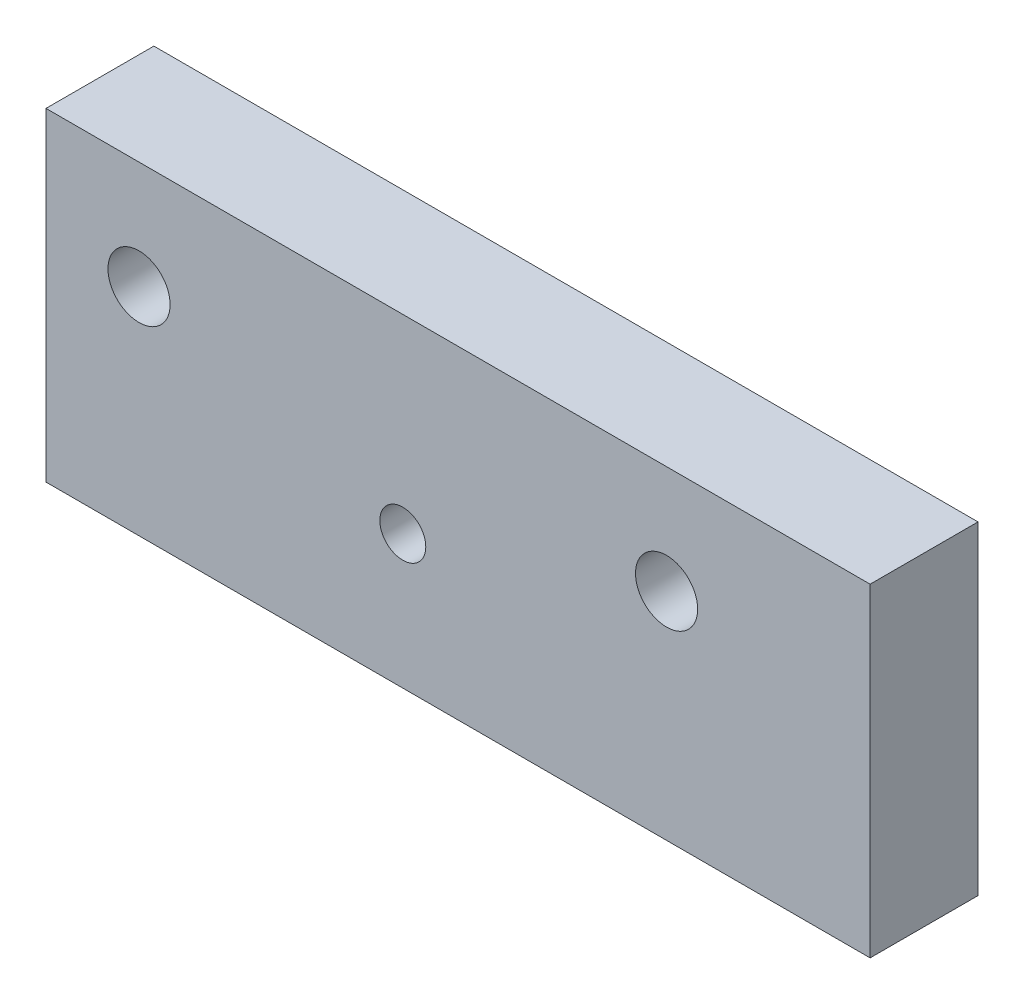
from build123d import *

# Parameters (mm, degrees)
SKETCH1_W                 = 48.505
SKETCH1_H                 = 19.05
BOSS_EXTRUDE1_DEPTH       = 6.35
F_6_CLEARANCE_HOLE1_D     = 3.6576
F_6_CLEARANCE_HOLE1_DEPTH = 9.398
F_6_CLEARANCE_HOLE1_TIP   = 1.0988539
SKETCH4_R                 = 4.7625
CUT_EXTRUDE1_DEPTH        = 2
F_6_32_TAPPED_HOLE1_D     = 2.7051
F_6_32_TAPPED_HOLE1_DEPTH = 10.9728
F_6_32_TAPPED_HOLE1_TIP   = 0.81269403


with BuildPart() as part:
    # Sketch1 → Boss-Extrude1 (new body)
    with BuildSketch(Plane.XY):
        with Locations((3.2525, -3.175)):
            Rectangle(SKETCH1_W, SKETCH1_H)
    extrude(amount=BOSS_EXTRUDE1_DEPTH)

    # 6 Clearance Hole1
    with Locations(Plane.XY.offset(6.35)):
        with Locations((-15.525, 0), (15.525, 0)):
            Hole(F_6_CLEARANCE_HOLE1_D / 2, depth=F_6_CLEARANCE_HOLE1_DEPTH)
            with Locations((0, 0, -(F_6_CLEARANCE_HOLE1_DEPTH + F_6_CLEARANCE_HOLE1_TIP / 2))):  # 118° drill point
                Cone(0, F_6_CLEARANCE_HOLE1_D / 2, F_6_CLEARANCE_HOLE1_TIP, mode=Mode.SUBTRACT)

    # Sketch4 → Cut-Extrude1 (cut)
    with BuildSketch(Plane(origin=(0, 0, 0), x_dir=(-1, 0, 0), z_dir=(0, 0, -1))):
        with Locations((-15.525, 0)):
            Circle(SKETCH4_R)
        with Locations((15.525, 0)):
            Circle(SKETCH4_R)
    extrude(amount=-CUT_EXTRUDE1_DEPTH, mode=Mode.SUBTRACT)

    # 6-32 Tapped Hole1
    with Locations(Plane(origin=(0, 0, 0), x_dir=(-1, 0, 0), z_dir=(0, 0, -1))):
        with Locations((0, -4.8294)):
            Hole(F_6_32_TAPPED_HOLE1_D / 2, depth=F_6_32_TAPPED_HOLE1_DEPTH)
            with Locations((0, 0, -(F_6_32_TAPPED_HOLE1_DEPTH + F_6_32_TAPPED_HOLE1_TIP / 2))):  # 118° drill point
                Cone(0, F_6_32_TAPPED_HOLE1_D / 2, F_6_32_TAPPED_HOLE1_TIP, mode=Mode.SUBTRACT)


solid = part.part
